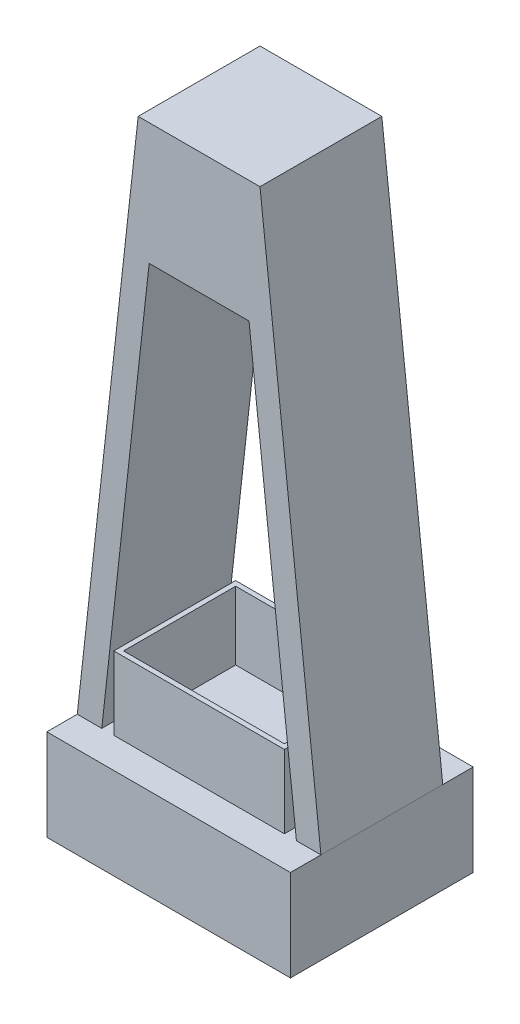
from build123d import *

# Parameters (mm, degrees)
BOSS_EXTRUDE1_DEPTH = 100
SKETCH3_W           = 200
SKETCH3_H           = 150
BOSS_EXTRUDE2_DEPTH = 75
CUT_EXTRUDE2_DEPTH  = 126
SKETCH6_W           = 140
SKETCH6_H           = 60
BOSS_EXTRUDE3_DEPTH = 100
SKETCH7_W           = 132
SKETCH7_H           = 92
CUT_EXTRUDE3_DEPTH  = 56


with BuildPart() as part:
    # Sketch2 → Boss-Extrude1 (new body)
    with BuildSketch(Plane.XY):
        Polygon((-50, 225), (50, 225), (100, -225), (-100, -225), align=None)
    extrude(amount=BOSS_EXTRUDE1_DEPTH)

    # Sketch3 → Boss-Extrude2 (add)
    with BuildSketch(Plane.XZ.offset(225)):
        with Locations((0, 50)):
            Rectangle(SKETCH3_W, SKETCH3_H)
    extrude(amount=BOSS_EXTRUDE2_DEPTH)

    # Sketch5 → Cut-Extrude2 (cut, through all)
    with BuildSketch(Plane(origin=(0, 0, 0), x_dir=(-1, 0, 0), z_dir=(0, 0, -1))):
        Polygon((-40.988033026, 125), (40.988033026, 125), (79.876921915, -225), (-79.876921915, -225), align=None)
    extrude(amount=-CUT_EXTRUDE2_DEPTH, mode=Mode.SUBTRACT)

    # Sketch6 → Boss-Extrude3 (add)
    with BuildSketch(Plane(origin=(0, 0, 0), x_dir=(-1, 0, 0), z_dir=(0, 0, -1))):
        with Locations((0, -195)):
            Rectangle(SKETCH6_W, SKETCH6_H)
    extrude(amount=-BOSS_EXTRUDE3_DEPTH)

    # Sketch7 → Cut-Extrude3 (cut)
    with BuildSketch(Plane(origin=(0, -165, 0), x_dir=(1, 0, 0), z_dir=(0, 1, 0))):
        with Locations((0, -50)):
            Rectangle(SKETCH7_W, SKETCH7_H)
    extrude(amount=-CUT_EXTRUDE3_DEPTH, mode=Mode.SUBTRACT)


solid = part.part
